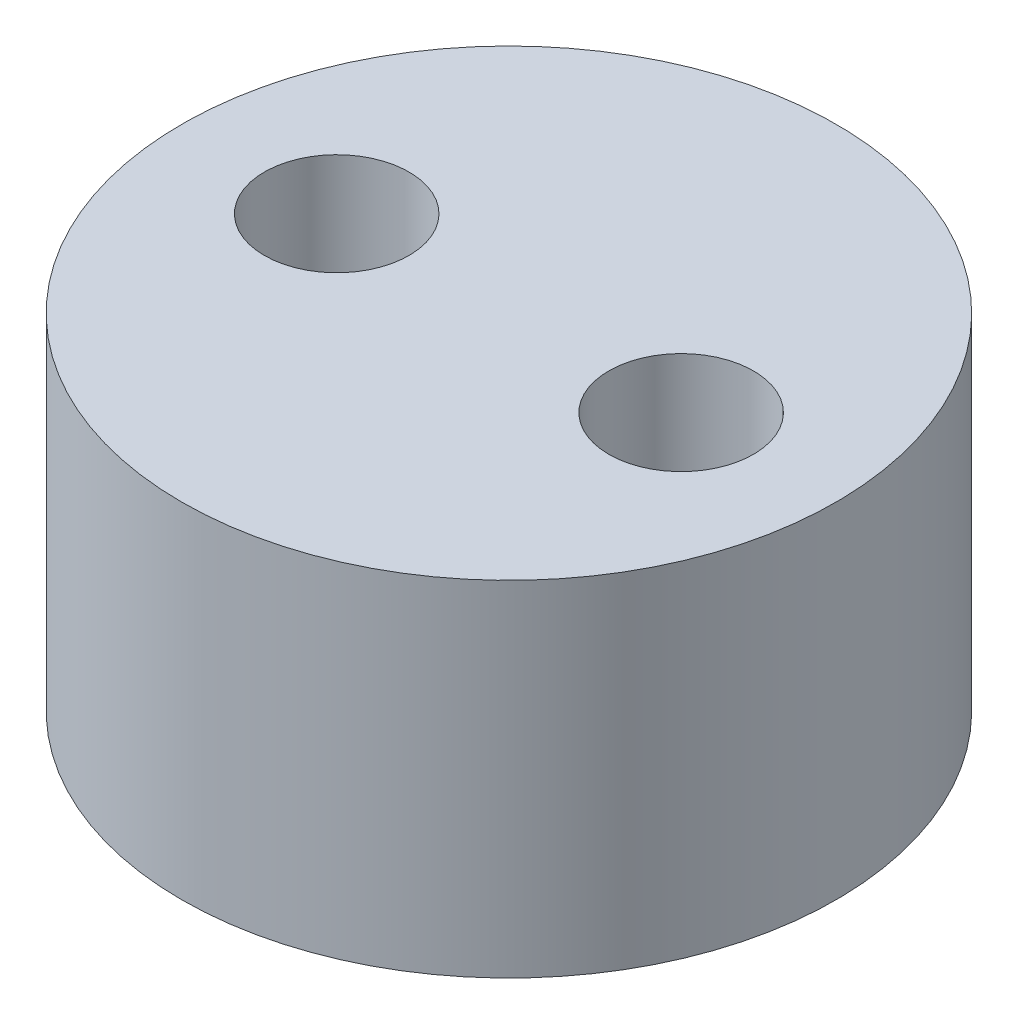
from build123d import *

# Parameters (mm, degrees)
SKETCH1_R           = 9.5
BOSS_EXTRUDE1_DEPTH = 10
CUT_EXTRUDE1_START  = -11
SKETCH2_R           = 2.1
CUT_EXTRUDE1_DEPTH  = 12


with BuildPart() as part:
    # Sketch1 → Boss-Extrude1 (new body)
    with BuildSketch(Plane(origin=(0, 0, 0), x_dir=(1, 0, 0), z_dir=(0, 1, 0))):
        Circle(SKETCH1_R)
    extrude(amount=BOSS_EXTRUDE1_DEPTH)

    # Sketch2 → Cut-Extrude1 (cut)
    with BuildSketch(Plane(origin=(0, 10, 0), x_dir=(1, 0, 0), z_dir=(0, 1, 0)).offset(CUT_EXTRUDE1_START)):
        with Locations((5, 0)):
            Circle(SKETCH2_R)
    cut_extrude1 = extrude(amount=CUT_EXTRUDE1_DEPTH, mode=Mode.SUBTRACT)

    # Mirror1: Cut-Extrude1 across plane
    add(cut_extrude1.mirror(Plane(origin=(0, 0, 0), x_dir=(0, 0, 1), z_dir=(1, 0, 0))), mode=Mode.SUBTRACT)


solid = part.part
